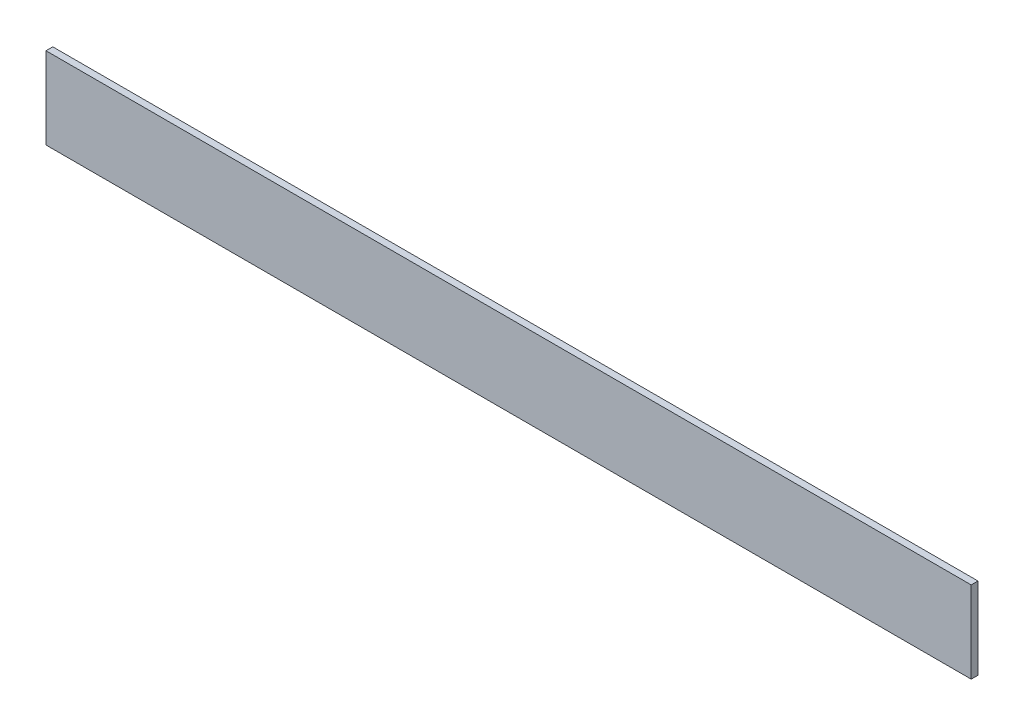
from build123d import *

# Parameters (mm, degrees)
SKETCH1_W           = 6.35
SKETCH1_H           = 76.2
BOSS_EXTRUDE1_DEPTH = 863.6


with BuildPart() as part:
    # Sketch1 → Boss-Extrude1 (new body)
    with BuildSketch(Plane(origin=(0, 0, 0), x_dir=(0, 0, -1), z_dir=(1, 0, 0))):
        Rectangle(SKETCH1_W, SKETCH1_H)
    extrude(amount=BOSS_EXTRUDE1_DEPTH)


solid = part.part
